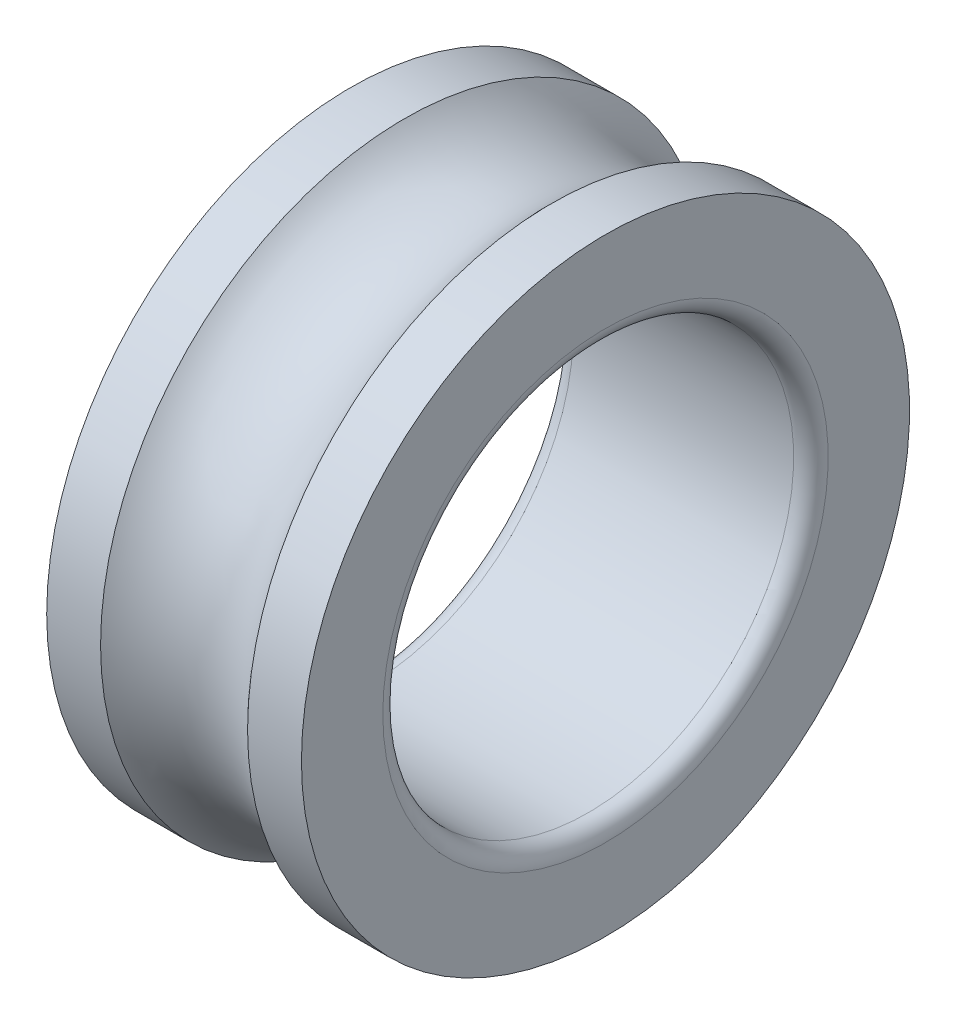
from build123d import *


with BuildPart() as part:
    # Sketch2 → Revolve1 (revolve)
    with BuildSketch(Plane(origin=(0, 0, 0), x_dir=(1, 0, 0), z_dir=(0, 1, 0))):
        with BuildLine():
            Line((-340.36, 635), (340.36, 635))
            ThreePointArc((340.36, 635), (378.077075708, 650.622924292), (393.7, 688.34))
            Line((393.7, 688.34), (393.7, 939.8))
            Line((393.7, 939.8), (227.184506514, 939.8))
            ThreePointArc((227.184506514, 939.8), (0, 838.2), (-227.184506514, 939.8))
            Line((-227.184506514, 939.8), (-393.7, 939.8))
            Line((-393.7, 939.8), (-393.7, 688.34))
            ThreePointArc((-393.7, 688.34), (-378.077075708, 650.622924292), (-340.36, 635))
        make_face()
    revolve(axis=Axis((-586.613, 0, 0), (1, 0, 0)))


solid = part.part
